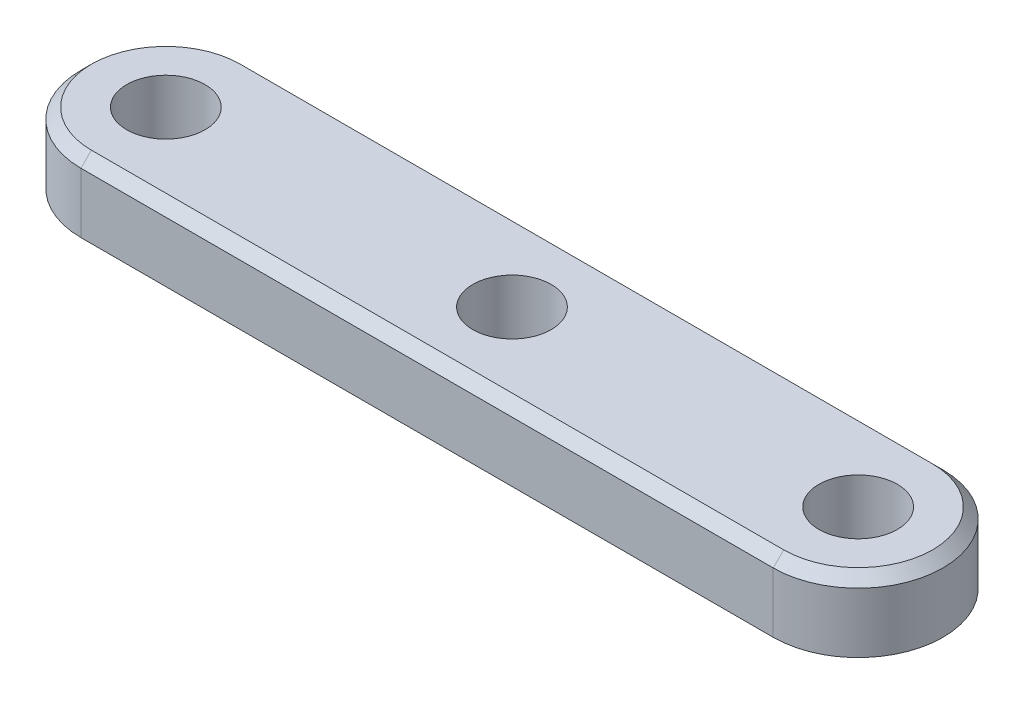
from build123d import *

# Parameters (mm, degrees)
SKETCH1_R           = 1.5
BOSS_EXTRUDE1_DEPTH = 1.35
CHAMFER1_SIZE       = 0.4


with BuildPart() as part:
    # Sketch1 → Boss-Extrude1 (new body, symmetric)
    with BuildSketch(Plane(origin=(0, 0, 0), x_dir=(1, 0, 0), z_dir=(0, 1, 0))):
        with BuildLine():
            Line((-13.25, 3.25), (13.25, 3.25))
            ThreePointArc((13.25, 3.25), (16.5, 0), (13.25, -3.25))
            Line((13.25, -3.25), (-13.25, -3.25))
            ThreePointArc((-13.25, -3.25), (-16.5, 0), (-13.25, 3.25))
        make_face()
        with Locations((-13.25, 0)):
            Circle(SKETCH1_R, mode=Mode.SUBTRACT)
        with Locations((13.25, 0)):
            Circle(SKETCH1_R, mode=Mode.SUBTRACT)
        Circle(SKETCH1_R, mode=Mode.SUBTRACT)
    extrude(amount=BOSS_EXTRUDE1_DEPTH, both=True)

    # Chamfer1
    chamfer1_edges = [part.edges().sort_by_distance(p)[0] for p in [
        (16.5, 1.35, 0),
        (0, 1.35, -3.25),
        (-16.5, 1.35, 0),
        (0, 1.35, 3.25),
    ]]
    chamfer(chamfer1_edges, length=CHAMFER1_SIZE)


solid = part.part
